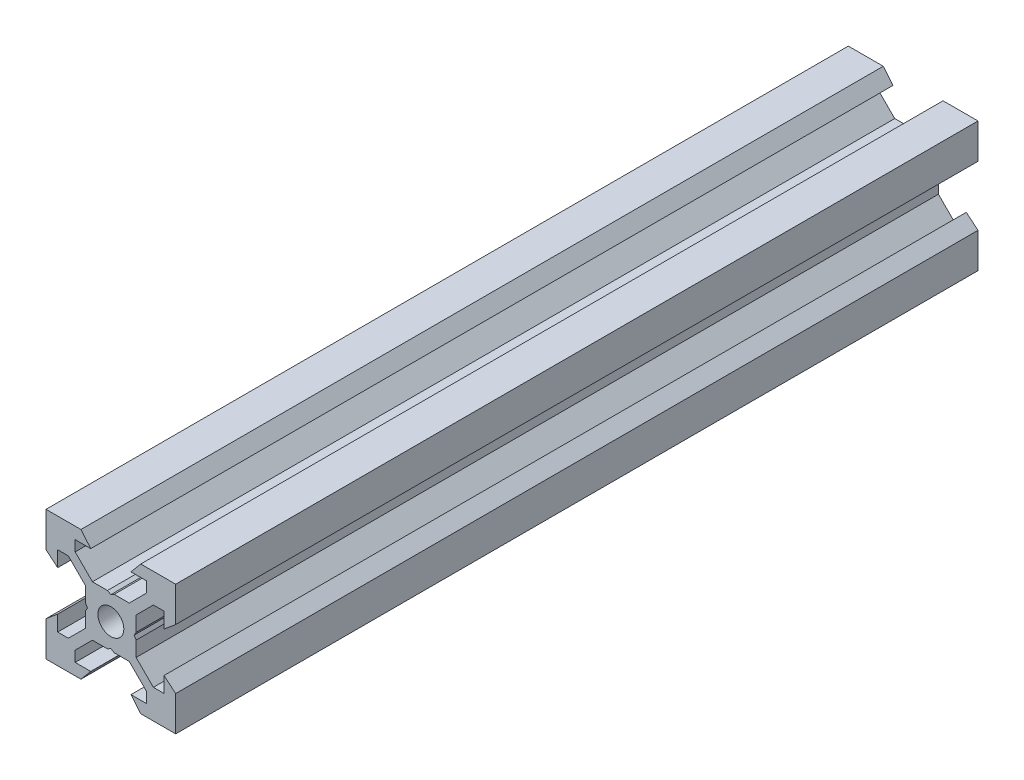
from build123d import *

# Parameters (mm, degrees)
SKETCH1_R           = 2
BOSS_EXTRUDE1_DEPTH = 61.87


with BuildPart() as part:
    # Sketch1 → Boss-Extrude1 (new body, symmetric)
    with BuildSketch(Plane.XY):
        Polygon((10, 10), (10, 4.610379336), (8.2, 3.1), (8.2, 5.5), (6.560660172, 5.5), (3.9, 2.839339828), (3.9, 0.519615242), (3.6, 0), (3.9, -0.519615242), (3.9, -2.839339828), (6.560660172, -5.5), (8.2, -5.5), (8.2, -3.1), (10, -4.610379336), (10, -10), (4.610379336, -10), (3.1, -8.2), (5.5, -8.2), (5.5, -6.560660172), (2.839339828, -3.9), (0.519615242, -3.9), (0, -3.6), (-0.519615242, -3.9), (-2.839339828, -3.9), (-5.5, -6.560660172), (-5.5, -8.2), (-3.1, -8.2), (-4.610379336, -10), (-10, -10), (-10, -4.610379336), (-8.2, -3.1), (-8.2, -5.5), (-6.560660172, -5.5), (-3.9, -2.839339828), (-3.9, -0.519615242), (-3.6, 0), (-3.9, 0.519615242), (-3.9, 2.839339828), (-6.560660172, 5.5), (-8.2, 5.5), (-8.2, 3.1), (-10, 4.610379336), (-10, 10), (-4.610379336, 10), (-3.1, 8.2), (-5.5, 8.2), (-5.5, 6.560660172), (-2.839339828, 3.9), (-0.519615242, 3.9), (0, 3.6), (0.519615242, 3.9), (2.839339828, 3.9), (5.5, 6.560660172), (5.5, 8.2), (3.1, 8.2), (4.610379336, 10), align=None)
        Circle(SKETCH1_R, mode=Mode.SUBTRACT)
    extrude(amount=BOSS_EXTRUDE1_DEPTH, both=True)


solid = part.part
